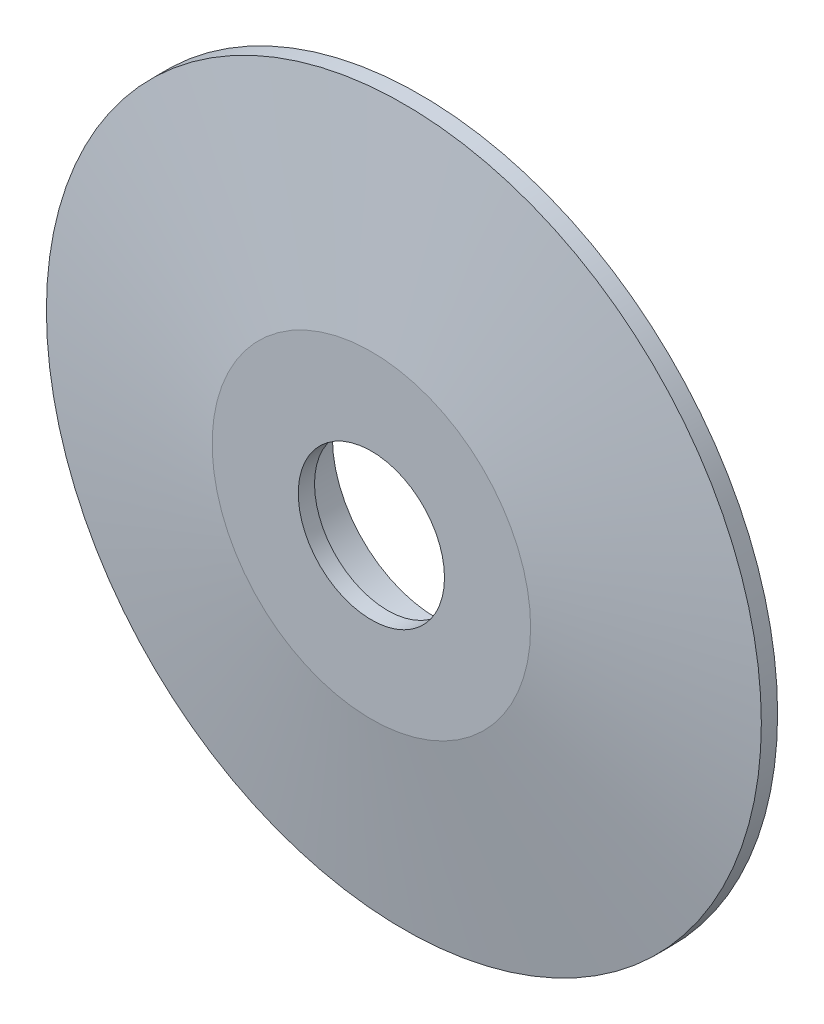
from build123d import *

# Parameters (mm, degrees)
SKETCH1_R           = 22.5
BOSS_EXTRUDE1_DEPTH = 15
SKETCH3_R           = 22.5
CUT_EXTRUDE1_DEPTH  = 43
SKETCH4_R           = 37
SKETCH4_R_2         = 32
BOSS_EXTRUDE2_DEPTH = 15


with BuildPart() as part:
    # Sketch1 → Boss-Extrude1 (new body)
    with BuildSketch(Plane.XY):
        Circle(SKETCH1_R)
    extrude(amount=BOSS_EXTRUDE1_DEPTH)

    # Sketch2 → Revolve1 (revolve)
    with BuildSketch(Plane(origin=(0, 0, 0), x_dir=(0, 0, -1), z_dir=(1, 0, 0))):
        Polygon((-15, 49), (-15, 22.5), (-10, 22.5), (-10, 48.592881079), (0, 109.592881079), (0, 110), (-5, 110), align=None)
    revolve(axis=Axis((0, 0, 15), (0, 0, -1)))

    # Sketch3 → Cut-Extrude1 (cut)
    with BuildSketch(Plane.XY.offset(15)):
        Circle(SKETCH3_R)
    extrude(amount=-CUT_EXTRUDE1_DEPTH, mode=Mode.SUBTRACT)

    # Sketch4 → Boss-Extrude2 (add)
    with BuildSketch(Plane(origin=(0, 0, 10), x_dir=(-1, 0, 0), z_dir=(0, 0, -1))):
        Circle(SKETCH4_R)
        Circle(SKETCH4_R_2, mode=Mode.SUBTRACT)
    extrude(amount=BOSS_EXTRUDE2_DEPTH)


solid = part.part
